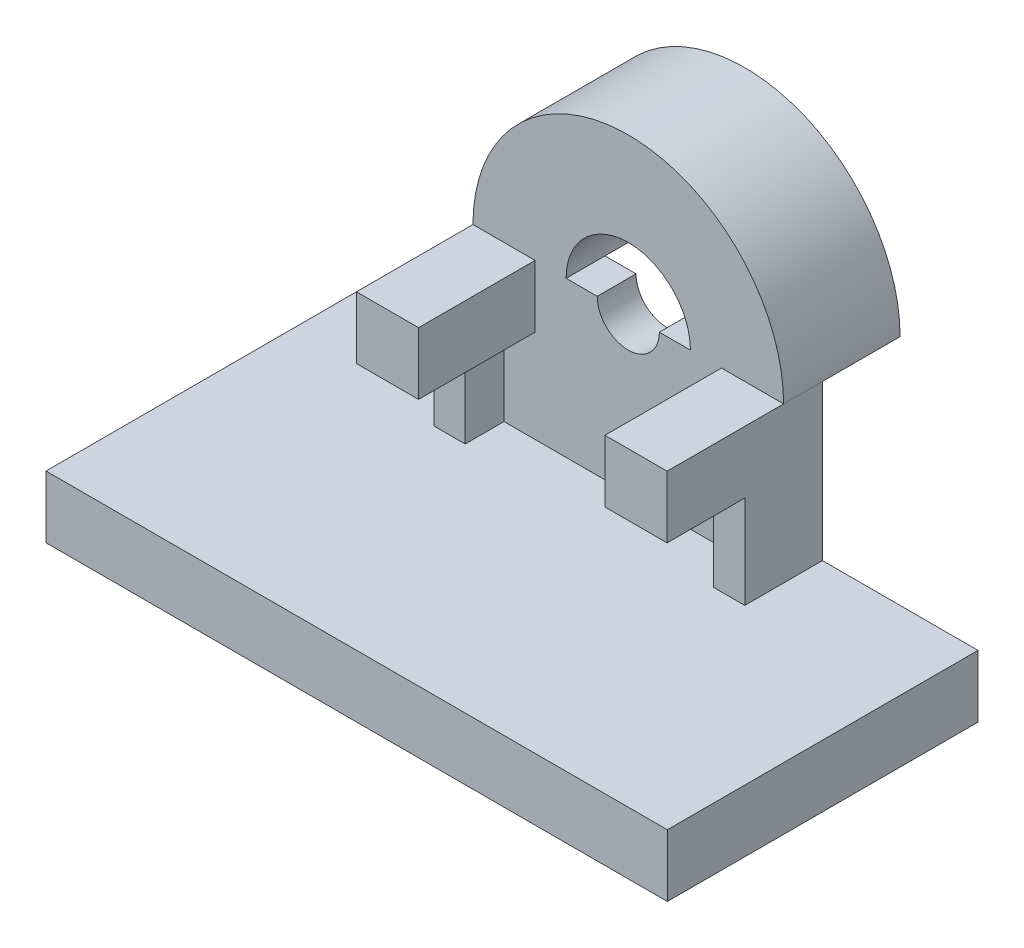
from build123d import *

# Parameters (mm, degrees)
BOSS_EXTRUDE1_DEPTH   = 50
SKETCH1_6_W           = 10
SKETCH1_6_H           = 10
BOSS_EXTRUDE2_DEPTH   = 25
BOSS_EXTRUDE2_2_DEPTH = 25
SKETCH1_7_W           = 5
SKETCH1_7_H           = 14.963037634
BOSS_EXTRUDE3_DEPTH   = 12.5
BOSS_EXTRUDE4_DEPTH   = 6.25
BOSS_EXTRUDE5_START   = -12.5
BOSS_EXTRUDE5_DEPTH   = 12.5


with BuildPart() as part:
    # Sketch1 → Boss-Extrude1 (new body)
    with BuildSketch(Plane.XY):
        Polygon((-43.094086022, -21.92641129), (-43.094086022, -31.92641129), (56.905913978, -31.92641129), (56.905913978, -21.92641129), (31.868951613, -21.92641129), (26.868951613, -21.92641129), (-13.131048387, -21.92641129), (-18.131048387, -21.92641129), align=None)
    extrude(amount=BOSS_EXTRUDE1_DEPTH)



with BuildPart() as body_2:
    # Sketch1_6 → Boss-Extrude2 (new body)
    with BuildSketch(Plane.XY):
        with Locations((-13.131048387, -1.963373656)):
            Rectangle(SKETCH1_6_W, SKETCH1_6_H)
    extrude(amount=BOSS_EXTRUDE2_DEPTH)


with BuildPart() as body_3:
    # Sketch1_6 → Boss-Extrude2 2 (new body)
    with BuildSketch(Plane.XY):
        with Locations((26.868951613, -1.963373656)):
            Rectangle(SKETCH1_6_W, SKETCH1_6_H)
    extrude(amount=BOSS_EXTRUDE2_2_DEPTH)


with BuildPart() as part_1:
    add(part.part)

    add(body_2.part)  # Boss-Extrude3 merges body 2

    add(body_3.part)  # Boss-Extrude3 merges body 3
    # Sketch1_7 → Boss-Extrude3 (add)
    with BuildSketch(Plane.XY):
        with Locations((-15.631048387, -14.444892473)):
            Rectangle(SKETCH1_7_W, SKETCH1_7_H)
        with Locations((29.368951613, -14.444892473)):
            Rectangle(SKETCH1_7_W, SKETCH1_7_H)
    extrude(amount=BOSS_EXTRUDE3_DEPTH)

    # Sketch1_8 → Boss-Extrude4 (add)
    with BuildSketch(Plane.XY):
        with BuildLine():
            Line((-13.131048387, -6.963373656), (-13.131048387, -21.92641129))
            Line((-13.131048387, -21.92641129), (26.868951613, -21.92641129))
            Line((26.868951613, -21.92641129), (26.868951613, -6.963373656))
            Line((26.868951613, -6.963373656), (21.868951613, -6.963373656))
            Line((21.868951613, -6.963373656), (21.868951613, 3.036626344))
            Line((21.868951613, 3.036626344), (31.868951613, 3.036626344))
            ThreePointArc((31.868951613, 3.036626344), (6.868951613, 28.036626344), (-18.131048387, 3.036626344))
            Line((-18.131048387, 3.036626344), (-8.131048387, 3.036626344))
            Line((-8.131048387, 3.036626344), (-8.131048387, -6.963373656))
            Line((-8.131048387, -6.963373656), (-13.131048387, -6.963373656))
        make_face()
        with BuildLine():
            Line((1.868951613, 3.036626344), (-3.131048387, 3.036626344))
            ThreePointArc((-3.131048387, 3.036626344), (6.868951613, 13.036626344), (16.868951613, 3.036626344))
            Line((16.868951613, 3.036626344), (11.868951613, 3.036626344))
            ThreePointArc((11.868951613, 3.036626344), (6.868951613, -1.963373656), (1.868951613, 3.036626344))
        make_face(mode=Mode.SUBTRACT)
    extrude(amount=BOSS_EXTRUDE4_DEPTH)

    # Sketch1_9 → Boss-Extrude5 (add)
    with BuildSketch(Plane.XY.offset(BOSS_EXTRUDE5_START)):
        with BuildLine():
            ThreePointArc((31.868951613, 3.036626344), (6.868951613, 28.036626344), (-18.131048387, 3.036626344))
            Line((-18.131048387, 3.036626344), (-8.131048387, 3.036626344))
            Line((-8.131048387, 3.036626344), (-3.131048387, 3.036626344))
            ThreePointArc((-3.131048387, 3.036626344), (6.868951613, 13.036626344), (16.868951613, 3.036626344))
            Line((16.868951613, 3.036626344), (21.868951613, 3.036626344))
            Line((21.868951613, 3.036626344), (31.868951613, 3.036626344))
        make_face()
    extrude(amount=BOSS_EXTRUDE5_DEPTH)


solid = part_1.part
